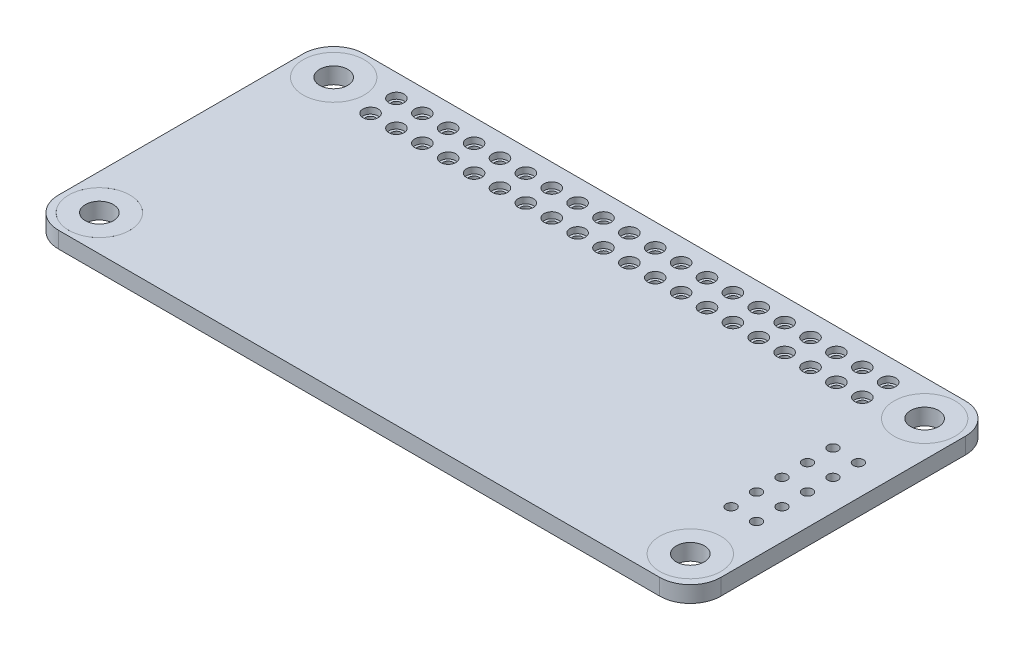
from build123d import *

# Parameters (mm, degrees)
SKETCH1_R                       = 3
SKETCH1_R_2                     = 0.75
BOSS_EXTRUDE1_DEPTH             = 1.6
SKETCH2_R                       = 0.75
SKETCH2_R_2                     = 0.5
BOSS_EXTRUDE2_DEPTH             = 1
LPATTERN2_COUNT                 = 20
LPATTERN2_PITCH                 = 2.54
LPATTERN2_2_COUNT               = 2
LPATTERN2_2_PITCH               = 2.54
SKETCH4_R                       = 3
SKETCH4_R_2                     = 1.375
BOSS_EXTRUDE4_DEPTH             = 1.6
ENL_V_START                     = -1
ESQUISSE1_R                     = 0.5
ENL_V_MAT_EXTRU_3_DEPTH         = 3.6
R_P_TITION_LIN_AIRE1_COUNT      = 5
R_P_TITION_LIN_AIRE1_PITCH      = 2.5
R_P_TITION_LIN_AIRE1_COUNT_DIR2 = 2
R_P_TITION_LIN_AIRE1_PITCH_DIR2 = 2.5


with BuildPart() as part:
    # Sketch1 → Boss-Extrude1 (new body)
    with BuildSketch(Plane(origin=(0, 0, 0), x_dir=(1, 0, 0), z_dir=(0, 1, 0))):
        with BuildLine():
            Line((-29.5, -15), (29.5, -15))
            ThreePointArc((29.5, -15), (31.621320344, -14.121320344), (32.5, -12))
            Line((32.5, -12), (32.5, 12))
            ThreePointArc((32.5, 12), (31.621320344, 14.121320344), (29.5, 15))
            Line((29.5, 15), (-29.5, 15))
            ThreePointArc((-29.5, 15), (-31.621320344, 14.121320344), (-32.5, 12))
            Line((-32.5, 12), (-32.5, -12))
            ThreePointArc((-32.5, -12), (-31.621320344, -14.121320344), (-29.5, -15))
        make_face()
        with Locations((-29, 11.5)):
            Circle(SKETCH1_R, mode=Mode.SUBTRACT)
        with Locations((-29, -11.5)):
            Circle(SKETCH1_R, mode=Mode.SUBTRACT)
        with Locations((29, -11.5)):
            Circle(SKETCH1_R, mode=Mode.SUBTRACT)
        with Locations((-24.13, 12.787653136)):
            Circle(SKETCH1_R_2, mode=Mode.SUBTRACT)
        with Locations((-21.59, 12.787653136)):
            Circle(SKETCH1_R_2, mode=Mode.SUBTRACT)
        with Locations((-19.05, 12.787653136)):
            Circle(SKETCH1_R_2, mode=Mode.SUBTRACT)
        with Locations((-16.51, 12.787653136)):
            Circle(SKETCH1_R_2, mode=Mode.SUBTRACT)
        with Locations((-13.97, 12.787653136)):
            Circle(SKETCH1_R_2, mode=Mode.SUBTRACT)
        with Locations((-11.43, 12.787653136)):
            Circle(SKETCH1_R_2, mode=Mode.SUBTRACT)
        with Locations((-8.89, 12.787653136)):
            Circle(SKETCH1_R_2, mode=Mode.SUBTRACT)
        with Locations((-6.35, 12.787653136)):
            Circle(SKETCH1_R_2, mode=Mode.SUBTRACT)
        with Locations((-3.81, 12.787653136)):
            Circle(SKETCH1_R_2, mode=Mode.SUBTRACT)
        with Locations((-1.27, 12.787653136)):
            Circle(SKETCH1_R_2, mode=Mode.SUBTRACT)
        with Locations((1.27, 12.787653136)):
            Circle(SKETCH1_R_2, mode=Mode.SUBTRACT)
        with Locations((3.81, 12.787653136)):
            Circle(SKETCH1_R_2, mode=Mode.SUBTRACT)
        with Locations((6.35, 12.787653136)):
            Circle(SKETCH1_R_2, mode=Mode.SUBTRACT)
        with Locations((8.89, 12.787653136)):
            Circle(SKETCH1_R_2, mode=Mode.SUBTRACT)
        with Locations((11.43, 12.787653136)):
            Circle(SKETCH1_R_2, mode=Mode.SUBTRACT)
        with Locations((13.97, 12.787653136)):
            Circle(SKETCH1_R_2, mode=Mode.SUBTRACT)
        with Locations((16.51, 12.787653136)):
            Circle(SKETCH1_R_2, mode=Mode.SUBTRACT)
        with Locations((19.05, 12.787653136)):
            Circle(SKETCH1_R_2, mode=Mode.SUBTRACT)
        with Locations((21.59, 12.787653136)):
            Circle(SKETCH1_R_2, mode=Mode.SUBTRACT)
        with Locations((24.13, 12.787653136)):
            Circle(SKETCH1_R_2, mode=Mode.SUBTRACT)
        with Locations((-21.59, 10.247653136)):
            Circle(SKETCH1_R_2, mode=Mode.SUBTRACT)
        with Locations((-19.05, 10.247653136)):
            Circle(SKETCH1_R_2, mode=Mode.SUBTRACT)
        with Locations((-16.51, 10.247653136)):
            Circle(SKETCH1_R_2, mode=Mode.SUBTRACT)
        with Locations((-13.97, 10.247653136)):
            Circle(SKETCH1_R_2, mode=Mode.SUBTRACT)
        with Locations((-11.43, 10.247653136)):
            Circle(SKETCH1_R_2, mode=Mode.SUBTRACT)
        with Locations((-8.89, 10.247653136)):
            Circle(SKETCH1_R_2, mode=Mode.SUBTRACT)
        with Locations((-6.35, 10.247653136)):
            Circle(SKETCH1_R_2, mode=Mode.SUBTRACT)
        with Locations((-3.81, 10.247653136)):
            Circle(SKETCH1_R_2, mode=Mode.SUBTRACT)
        with Locations((-1.27, 10.247653136)):
            Circle(SKETCH1_R_2, mode=Mode.SUBTRACT)
        with Locations((1.27, 10.247653136)):
            Circle(SKETCH1_R_2, mode=Mode.SUBTRACT)
        with Locations((3.81, 10.247653136)):
            Circle(SKETCH1_R_2, mode=Mode.SUBTRACT)
        with Locations((6.35, 10.247653136)):
            Circle(SKETCH1_R_2, mode=Mode.SUBTRACT)
        with Locations((8.89, 10.247653136)):
            Circle(SKETCH1_R_2, mode=Mode.SUBTRACT)
        with Locations((11.43, 10.247653136)):
            Circle(SKETCH1_R_2, mode=Mode.SUBTRACT)
        with Locations((13.97, 10.247653136)):
            Circle(SKETCH1_R_2, mode=Mode.SUBTRACT)
        with Locations((16.51, 10.247653136)):
            Circle(SKETCH1_R_2, mode=Mode.SUBTRACT)
        with Locations((19.05, 10.247653136)):
            Circle(SKETCH1_R_2, mode=Mode.SUBTRACT)
        with Locations((21.59, 10.247653136)):
            Circle(SKETCH1_R_2, mode=Mode.SUBTRACT)
        with Locations((24.13, 10.247653136)):
            Circle(SKETCH1_R_2, mode=Mode.SUBTRACT)
        with Locations((-24.13, 10.247653136)):
            Circle(SKETCH1_R_2, mode=Mode.SUBTRACT)
        with Locations((29, 11.5)):
            Circle(SKETCH1_R, mode=Mode.SUBTRACT)
    extrude(amount=BOSS_EXTRUDE1_DEPTH)

    # Esquisse1 → Enlèv. mat.-Extru.3 (cut)
    with BuildSketch(Plane(origin=(0, 0, 0), x_dir=(1, 0, 0), z_dir=(0, 1, 0)).offset(ENL_V_START)):
        with Locations((29.5, 4.5)):
            Circle(ESQUISSE1_R)
    enl_v_mat_extru_3 = extrude(amount=ENL_V_MAT_EXTRU_3_DEPTH, mode=Mode.SUBTRACT)

    # Répétition linéaire1: Enl_v. mat.-Extru.3 5 × 2
    with Locations(*[(-j * R_P_TITION_LIN_AIRE1_PITCH_DIR2, 0, i * R_P_TITION_LIN_AIRE1_PITCH) for i in range(R_P_TITION_LIN_AIRE1_COUNT) for j in range(R_P_TITION_LIN_AIRE1_COUNT_DIR2) if (i, j) != (0, 0)]):
        add(enl_v_mat_extru_3, mode=Mode.SUBTRACT)


with BuildPart() as body_2:
    # Sketch2 → Boss-Extrude2 (new body)
    with BuildSketch(Plane(origin=(0, 0, 0), x_dir=(1, 0, 0), z_dir=(0, 1, 0))):
        with Locations((-24.13, 12.787653136)):
            Circle(SKETCH2_R)
        with Locations((-24.13, 12.787653136)):
            Circle(SKETCH2_R_2, mode=Mode.SUBTRACT)
    extrude(amount=BOSS_EXTRUDE2_DEPTH)


with BuildPart() as lpattern2_1:
    # LPattern2: pattern copy
    add(body_2.part.moved(Location(Vector(1, 0, 0) * (1 * LPATTERN2_PITCH))))


with BuildPart() as lpattern2_2:
    # LPattern2: pattern copy
    add(body_2.part.moved(Location(Vector(1, 0, 0) * (2 * LPATTERN2_PITCH))))


with BuildPart() as lpattern2_3:
    # LPattern2: pattern copy
    add(body_2.part.moved(Location(Vector(1, 0, 0) * (3 * LPATTERN2_PITCH))))


with BuildPart() as lpattern2_4:
    # LPattern2: pattern copy
    add(body_2.part.moved(Location(Vector(1, 0, 0) * (4 * LPATTERN2_PITCH))))


with BuildPart() as lpattern2_5:
    # LPattern2: pattern copy
    add(body_2.part.moved(Location(Vector(1, 0, 0) * (5 * LPATTERN2_PITCH))))


with BuildPart() as lpattern2_6:
    # LPattern2: pattern copy
    add(body_2.part.moved(Location(Vector(1, 0, 0) * (6 * LPATTERN2_PITCH))))


with BuildPart() as lpattern2_7:
    # LPattern2: pattern copy
    add(body_2.part.moved(Location(Vector(1, 0, 0) * (7 * LPATTERN2_PITCH))))


with BuildPart() as lpattern2_8:
    # LPattern2: pattern copy
    add(body_2.part.moved(Location(Vector(1, 0, 0) * (8 * LPATTERN2_PITCH))))


with BuildPart() as lpattern2_9:
    # LPattern2: pattern copy
    add(body_2.part.moved(Location(Vector(1, 0, 0) * (9 * LPATTERN2_PITCH))))


with BuildPart() as lpattern2_10:
    # LPattern2: pattern copy
    add(body_2.part.moved(Location(Vector(1, 0, 0) * (10 * LPATTERN2_PITCH))))


with BuildPart() as lpattern2_11:
    # LPattern2: pattern copy
    add(body_2.part.moved(Location(Vector(1, 0, 0) * (11 * LPATTERN2_PITCH))))


with BuildPart() as lpattern2_12:
    # LPattern2: pattern copy
    add(body_2.part.moved(Location(Vector(1, 0, 0) * (12 * LPATTERN2_PITCH))))


with BuildPart() as lpattern2_13:
    # LPattern2: pattern copy
    add(body_2.part.moved(Location(Vector(1, 0, 0) * (13 * LPATTERN2_PITCH))))


with BuildPart() as lpattern2_14:
    # LPattern2: pattern copy
    add(body_2.part.moved(Location(Vector(1, 0, 0) * (14 * LPATTERN2_PITCH))))


with BuildPart() as lpattern2_15:
    # LPattern2: pattern copy
    add(body_2.part.moved(Location(Vector(1, 0, 0) * (15 * LPATTERN2_PITCH))))


with BuildPart() as lpattern2_16:
    # LPattern2: pattern copy
    add(body_2.part.moved(Location(Vector(1, 0, 0) * (16 * LPATTERN2_PITCH))))


with BuildPart() as lpattern2_17:
    # LPattern2: pattern copy
    add(body_2.part.moved(Location(Vector(1, 0, 0) * (17 * LPATTERN2_PITCH))))


with BuildPart() as lpattern2_18:
    # LPattern2: pattern copy
    add(body_2.part.moved(Location(Vector(1, 0, 0) * (18 * LPATTERN2_PITCH))))


with BuildPart() as lpattern2_19:
    # LPattern2: pattern copy
    add(body_2.part.moved(Location(Vector(1, 0, 0) * (19 * LPATTERN2_PITCH))))


with BuildPart() as lpattern2_2_1:
    # LPattern2 2: pattern copy
    add(body_2.part.moved(Location(Vector(0, 0, 1) * (1 * LPATTERN2_2_PITCH))))


with BuildPart() as lpattern2_2_2:
    # LPattern2 2: pattern copy
    add(lpattern2_1.part.moved(Location(Vector(0, 0, 1) * (1 * LPATTERN2_2_PITCH))))


with BuildPart() as lpattern2_2_3:
    # LPattern2 2: pattern copy
    add(lpattern2_2.part.moved(Location(Vector(0, 0, 1) * (1 * LPATTERN2_2_PITCH))))


with BuildPart() as lpattern2_2_4:
    # LPattern2 2: pattern copy
    add(lpattern2_3.part.moved(Location(Vector(0, 0, 1) * (1 * LPATTERN2_2_PITCH))))


with BuildPart() as lpattern2_2_5:
    # LPattern2 2: pattern copy
    add(lpattern2_4.part.moved(Location(Vector(0, 0, 1) * (1 * LPATTERN2_2_PITCH))))


with BuildPart() as lpattern2_2_6:
    # LPattern2 2: pattern copy
    add(lpattern2_5.part.moved(Location(Vector(0, 0, 1) * (1 * LPATTERN2_2_PITCH))))


with BuildPart() as lpattern2_2_7:
    # LPattern2 2: pattern copy
    add(lpattern2_6.part.moved(Location(Vector(0, 0, 1) * (1 * LPATTERN2_2_PITCH))))


with BuildPart() as lpattern2_2_8:
    # LPattern2 2: pattern copy
    add(lpattern2_7.part.moved(Location(Vector(0, 0, 1) * (1 * LPATTERN2_2_PITCH))))


with BuildPart() as lpattern2_2_9:
    # LPattern2 2: pattern copy
    add(lpattern2_8.part.moved(Location(Vector(0, 0, 1) * (1 * LPATTERN2_2_PITCH))))


with BuildPart() as lpattern2_2_10:
    # LPattern2 2: pattern copy
    add(lpattern2_9.part.moved(Location(Vector(0, 0, 1) * (1 * LPATTERN2_2_PITCH))))


with BuildPart() as lpattern2_2_11:
    # LPattern2 2: pattern copy
    add(lpattern2_10.part.moved(Location(Vector(0, 0, 1) * (1 * LPATTERN2_2_PITCH))))


with BuildPart() as lpattern2_2_12:
    # LPattern2 2: pattern copy
    add(lpattern2_11.part.moved(Location(Vector(0, 0, 1) * (1 * LPATTERN2_2_PITCH))))


with BuildPart() as lpattern2_2_13:
    # LPattern2 2: pattern copy
    add(lpattern2_12.part.moved(Location(Vector(0, 0, 1) * (1 * LPATTERN2_2_PITCH))))


with BuildPart() as lpattern2_2_14:
    # LPattern2 2: pattern copy
    add(lpattern2_13.part.moved(Location(Vector(0, 0, 1) * (1 * LPATTERN2_2_PITCH))))


with BuildPart() as lpattern2_2_15:
    # LPattern2 2: pattern copy
    add(lpattern2_14.part.moved(Location(Vector(0, 0, 1) * (1 * LPATTERN2_2_PITCH))))


with BuildPart() as lpattern2_2_16:
    # LPattern2 2: pattern copy
    add(lpattern2_15.part.moved(Location(Vector(0, 0, 1) * (1 * LPATTERN2_2_PITCH))))


with BuildPart() as lpattern2_2_17:
    # LPattern2 2: pattern copy
    add(lpattern2_16.part.moved(Location(Vector(0, 0, 1) * (1 * LPATTERN2_2_PITCH))))


with BuildPart() as lpattern2_2_18:
    # LPattern2 2: pattern copy
    add(lpattern2_17.part.moved(Location(Vector(0, 0, 1) * (1 * LPATTERN2_2_PITCH))))


with BuildPart() as lpattern2_2_19:
    # LPattern2 2: pattern copy
    add(lpattern2_18.part.moved(Location(Vector(0, 0, 1) * (1 * LPATTERN2_2_PITCH))))


with BuildPart() as lpattern2_2_20:
    # LPattern2 2: pattern copy
    add(lpattern2_19.part.moved(Location(Vector(0, 0, 1) * (1 * LPATTERN2_2_PITCH))))


with BuildPart() as body_42:
    # Sketch4 → Boss-Extrude4 (new body)
    with BuildSketch(Plane(origin=(0, 0, 0), x_dir=(1, 0, 0), z_dir=(0, 1, 0))):
        with Locations((-29, 11.5)):
            Circle(SKETCH4_R)
        with Locations((-29, 11.5)):
            Circle(SKETCH4_R_2, mode=Mode.SUBTRACT)
    extrude(amount=BOSS_EXTRUDE4_DEPTH)


with BuildPart() as body_43:
    # Mirror1: mirrored copy
    add(body_42.part.mirror(Plane(origin=(0, 0, 0), x_dir=(0, 0, 1), z_dir=(1, 0, 0))))


with BuildPart() as body_44:
    # Mirror2: mirrored copy
    add(body_42.part.mirror(Plane.XY))


with BuildPart() as body_45:
    # Mirror2 2: mirrored copy
    add(body_43.part.mirror(Plane.XY))


solid = Compound([part.part, body_2.part, lpattern2_1.part, lpattern2_2.part, lpattern2_3.part, lpattern2_4.part, lpattern2_5.part, lpattern2_6.part, lpattern2_7.part, lpattern2_8.part, lpattern2_9.part, lpattern2_10.part, lpattern2_11.part, lpattern2_12.part, lpattern2_13.part, lpattern2_14.part, lpattern2_15.part, lpattern2_16.part, lpattern2_17.part, lpattern2_18.part, lpattern2_19.part, lpattern2_2_1.part, lpattern2_2_2.part, lpattern2_2_3.part, lpattern2_2_4.part, lpattern2_2_5.part, lpattern2_2_6.part, lpattern2_2_7.part, lpattern2_2_8.part, lpattern2_2_9.part, lpattern2_2_10.part, lpattern2_2_11.part, lpattern2_2_12.part, lpattern2_2_13.part, lpattern2_2_14.part, lpattern2_2_15.part, lpattern2_2_16.part, lpattern2_2_17.part, lpattern2_2_18.part, lpattern2_2_19.part, lpattern2_2_20.part, body_42.part, body_43.part, body_44.part, body_45.part])
